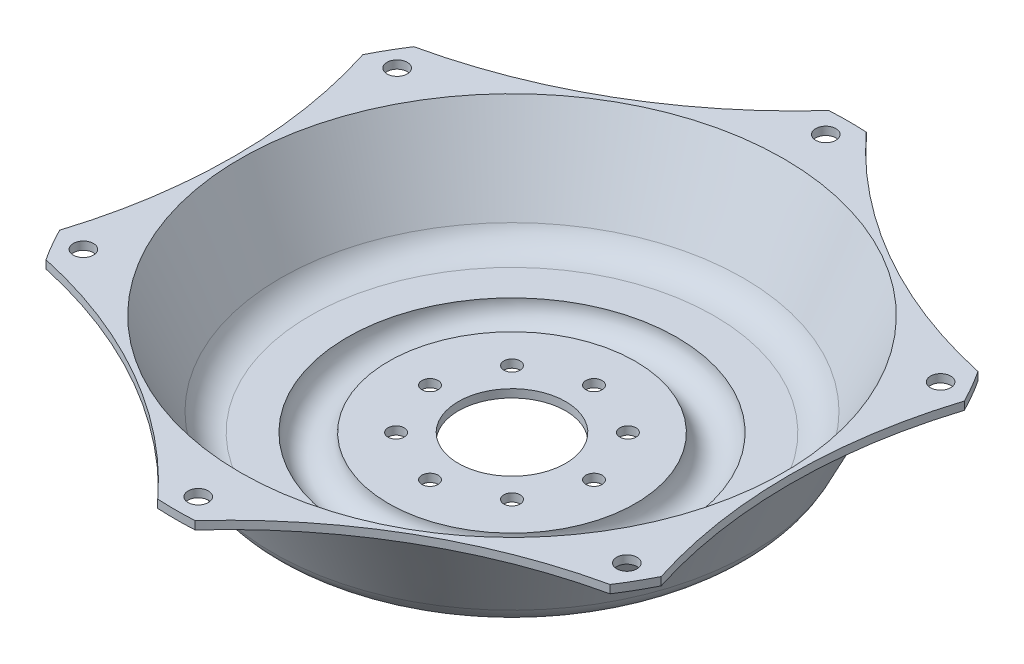
from build123d import *

# Parameters (mm, degrees)
THICKEN1_T1                      = 8
CUT_EXTRUDE1_DEPTH               = 486.420178839
CIRPATTERN1_COUNT                = 6
F_16_0MM_DOWEL_HOLE2_D           = 16
F_16_0MM_DOWEL_HOLE2_CSINK_D     = 16.05
F_16_0MM_DOWEL_HOLE2_CSINK_ANGLE = 90
CIRPATTERN2_COUNT                = 8


with BuildPart() as body_1:
    # Surface-Revolve1: a surface, the sketch's curves turned about an axis
    with BuildLine(Plane.XY, mode=Mode.PRIVATE) as surface_revolve1_1_path:
        Line((53, 0), (115, 0))
        ThreePointArc((115, 0), (142.354158733, -20.5), (169.708317466, 0))
        Line((169.708317466, 0), (199.708317466, 0))
        ThreePointArc((199.708317466, 0), (220.905088036, 6.078076154), (235.660079318, 22.465154128))
        Line((235.660079318, 22.465154128), (273.476350399, 100))
        Line((273.476350399, 100), (332.5, 100))
    surface_revolve1_1 = Shell.revolve(surface_revolve1_1_path.wire(), 360, Axis((0, 88.516727843, 0), (0, -1, 0)))
    add(Solid.thicken(surface_revolve1_1, THICKEN1_T1))

    # Sketch2 → Cut-Extrude1 (cut, through all)
    with BuildSketch(Plane.XZ.offset(-100)):
        with BuildLine():
            ThreePointArc((-278.018608961, 182.378461095), (-136.404500662, 237.029800715), (-18, 332.012424466))
            ThreePointArc((-18, 332.012424466), (-165.844309403, 288.187291598), (-278.018608961, 182.378461095))
        make_face()
        with BuildLine():
            ThreePointArc((0, 320), (-10, 310), (0, 300))
            Line((0, 300), (0, 320))
        make_face()
        with BuildLine():
            Line((0, 320), (0, 300))
            ThreePointArc((0, 300), (7.071067812, 302.928932188), (10, 310))
            ThreePointArc((10, 310), (7.071067812, 317.071067812), (0, 320))
        make_face()
    cut_extrude1 = extrude(amount=-CUT_EXTRUDE1_DEPTH, mode=Mode.SUBTRACT)

    # CirPattern1: Cut-Extrude1 ×6 about axis
    cirpattern1_axis = Axis((0, 0, 0), (0, 1, 0))
    for i in range(1, CIRPATTERN1_COUNT):
        add(cut_extrude1.rotate(cirpattern1_axis, i * 360 / CIRPATTERN1_COUNT), mode=Mode.SUBTRACT)

    # 16.0mm Dowel Hole2 (through all)
    with Locations(Plane(origin=(0, 0, 0), x_dir=(-1, 0, 0), z_dir=(0, -1, 0))):
        with Locations((0, 81)):
            f_16_0mm_dowel_hole2 = CounterSinkHole(F_16_0MM_DOWEL_HOLE2_D / 2, F_16_0MM_DOWEL_HOLE2_CSINK_D / 2, counter_sink_angle=F_16_0MM_DOWEL_HOLE2_CSINK_ANGLE)

    # CirPattern2: 16.0mm Dowel Hole2 ×8 about axis
    cirpattern2_axis = Axis((0, 0, 0), (0, 1, 0))
    for i in range(1, CIRPATTERN2_COUNT):
        add(f_16_0mm_dowel_hole2.rotate(cirpattern2_axis, i * 360 / CIRPATTERN2_COUNT), mode=Mode.SUBTRACT)


solid = body_1.part
